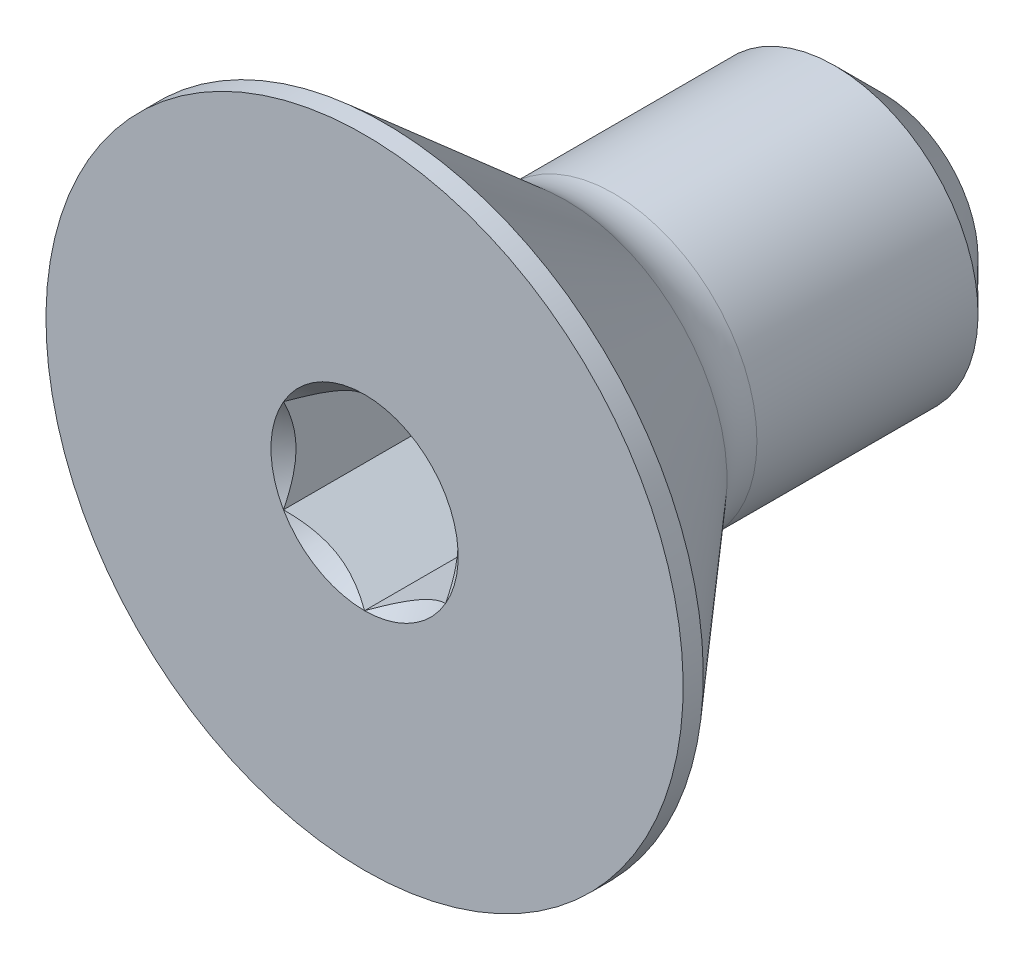
from build123d import *

# Parameters (mm, degrees)
SKETCH12_W         = 6.35
SKETCH12_H         = 1.7526
CHAMFER1_SIZE      = 0.5953125
CUT_EXTRUDE2_DEPTH = 1.72466


with BuildPart() as part:
    # Sketch12 → Revolve3 (revolve)
    with BuildSketch(Plane(origin=(0, 0, 0), x_dir=(0, 0, -1), z_dir=(1, 0, 0))):
        with Locations((0, 0.8763)):
            Rectangle(SKETCH12_W, SKETCH12_H)
    revolve(axis=Axis((0, 0, -3.175), (0, 0, 1)))

    # Sketch7 → Revolve2 (revolve)
    with BuildSketch(Plane(origin=(0, 0, 0), x_dir=(0, 0, -1), z_dir=(1, 0, 0))):
        with BuildLine():
            Line((-3.175, 3.8989), (-2.92862, 3.8989))
            Line((-2.92862, 3.8989), (-0.7112, 1.971326202))
            ThreePointArc((-0.7112, 1.971326202), (-0.43847117, 1.809069598), (-0.126190199, 1.7526))
            Line((-0.126190199, 1.7526), (-0.126190199, 0))
            Line((-0.126190199, 0), (-3.175, 0))
            Line((-3.175, 0), (-3.175, 3.8989))
        make_face()
    revolve(axis=Axis((0, 0, 3.175), (0, 0, -1)))

    # Chamfer1
    chamfer1_edges = [part.edges().sort_by_distance(p)[0] for p in [
        (0, -1.7526, -3.175),
    ]]
    chamfer(chamfer1_edges, length=CHAMFER1_SIZE)

    # Sketch5 → Cut-Extrude2 (cut)
    with BuildSketch(Plane.XY.offset(3.175)):
        Polygon((0, 1.14567944), (-0.9921875, 0.57283972), (-0.9921875, -0.57283972), (0, -1.14567944), (0.9921875, -0.57283972), (0.9921875, 0.57283972), align=None)
    extrude(amount=-CUT_EXTRUDE2_DEPTH, mode=Mode.SUBTRACT)

    # Cut-Extrude3 cone 1 section (through the dimple's axis) → Cut-Extrude3 (revolve, cut)
    with BuildSketch(Plane(origin=(0, 0, 3.175), x_dir=(0, -1, 0), z_dir=(1, 0, 0))):
        Polygon((0, 0), (1.14567944, 0), (0, 1.14567944), align=None)
    revolve(axis=Axis((0, 0, 3.175), (0, 0, -1)), mode=Mode.SUBTRACT)


solid = part.part
